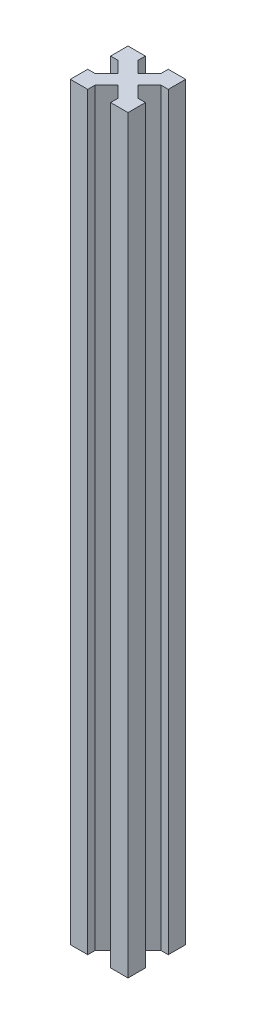
from build123d import *

# Parameters (mm, degrees)
BOSS_EXTRU_1_DEPTH = 260


with BuildPart() as part:
    # Esquisse1 → Boss.-Extru.1 (new body)
    with BuildSketch(Plane(origin=(0, 0, 0), x_dir=(1, 0, 0), z_dir=(0, 1, 0))):
        Polygon((-3.535533906, 0), (-6.035533906, 2.5), (-6.035533906, 0), align=None)
        Polygon((0, 3.535533906), (-2.5, 6.035533906), (-2.5, 2.5), (-6.035533906, 2.5), (-3.535533906, 0), (0, 0), align=None)
        Polygon((0, 6.035533906), (-2.5, 6.035533906), (0, 3.535533906), align=None)
        Polygon((-2.5, 2.5), (-2.5, 6.035533906), (-6.464466094, 10), (-10, 6.464466094), (-6.035533906, 2.5), align=None)
        Polygon((-13.964466094, 0), (-13.964466094, 2.5), (-16.464466094, 0), align=None)
        Polygon((-17.5, 2.5), (-17.5, 6.035533906), (-20, 3.535533906), (-20, 0), (-16.464466094, 0), (-13.964466094, 2.5), align=None)
        Polygon((-20, 3.535533906), (-17.5, 6.035533906), (-20, 6.035533906), align=None)
        Polygon((-10, 6.464466094), (-13.535533906, 10), (-17.5, 6.035533906), (-17.5, 2.5), (-13.964466094, 2.5), align=None)
        Polygon((-6.464466094, 10), (-10, 13.535533906), (-13.535533906, 10), (-10, 6.464466094), align=None)
        Polygon((-2.5, 13.964466094), (-2.5, 17.5), (-6.035533906, 17.5), (-10, 13.535533906), (-6.464466094, 10), align=None)
        Polygon((-6.035533906, 17.5), (-2.5, 17.5), (-2.5, 13.964466094), (0, 16.464466094), (0, 20), (-3.535533906, 20), align=None)
        Polygon((0, 16.464466094), (-2.5, 13.964466094), (0, 13.964466094), align=None)
        Polygon((-6.035533906, 20), (-6.035533906, 17.5), (-3.535533906, 20), align=None)
        Polygon((-16.464466094, 20), (-13.964466094, 17.5), (-13.964466094, 20), align=None)
        Polygon((-17.5, 17.5), (-13.964466094, 17.5), (-16.464466094, 20), (-20, 20), (-20, 16.464466094), (-17.5, 13.964466094), align=None)
        Polygon((-20, 13.964466094), (-17.5, 13.964466094), (-20, 16.464466094), align=None)
        Polygon((-10, 13.535533906), (-13.964466094, 17.5), (-17.5, 17.5), (-17.5, 13.964466094), (-13.535533906, 10), align=None)
    extrude(amount=BOSS_EXTRU_1_DEPTH)


solid = part.part
